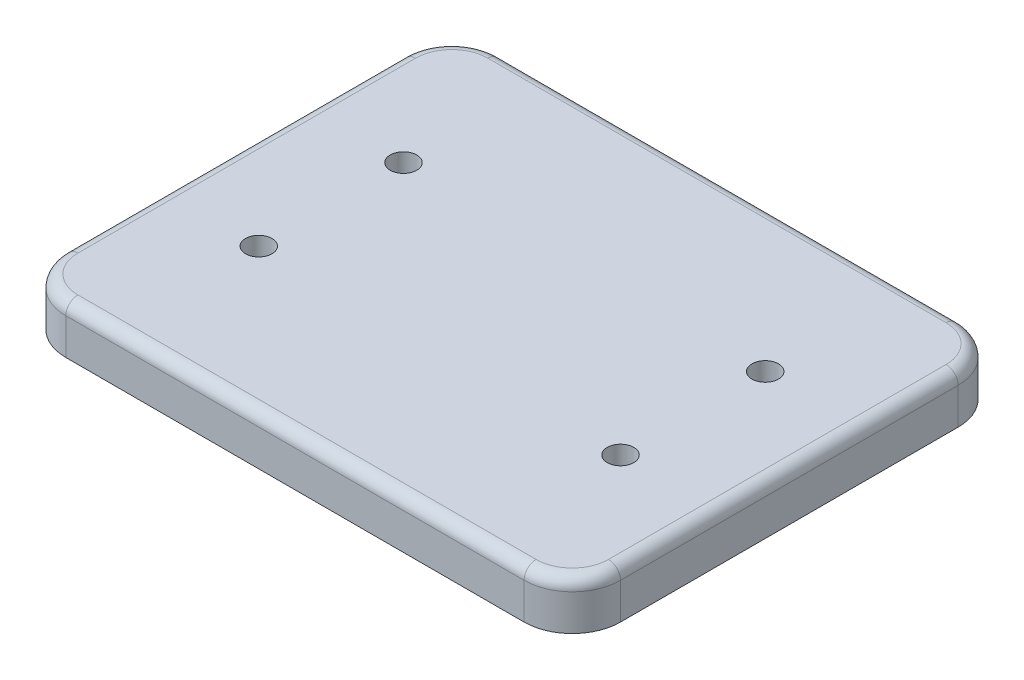
from build123d import *

# Parameters (mm, degrees)
BOSS_EXTRUDE1_DEPTH = 20
FILLET1_R           = 5
SKETCH2_R           = 5.5
CUT_EXTRUDE1_DEPTH  = 21
SKETCH3_R           = 9
CUT_EXTRUDE2_DEPTH  = 11


with BuildPart() as part:
    # Sketch1 → Boss-Extrude1 (new body)
    with BuildSketch(Plane(origin=(0, 0, 0), x_dir=(1, 0, 0), z_dir=(0, 1, 0))):
        with BuildLine():
            Line((-115, 70), (-115, -70))
            ThreePointArc((-115, -70), (-109.142135624, -84.142135624), (-95, -90))
            Line((-95, -90), (95, -90))
            ThreePointArc((95, -90), (109.142135624, -84.142135624), (115, -70))
            Line((115, -70), (115, 70))
            ThreePointArc((115, 70), (109.142135624, 84.142135624), (95, 90))
            Line((95, 90), (-95, 90))
            ThreePointArc((-95, 90), (-109.142135624, 84.142135624), (-115, 70))
        make_face()
    extrude(amount=BOSS_EXTRUDE1_DEPTH)

    # Fillet1
    fillet1_edges = [part.edges().sort_by_distance(p)[0] for p in [
        (109.142135624, 20, 84.142135624),
        (115, 20, 0),
        (109.142135624, 20, -84.142135624),
        (0, 20, -90),
        (-109.142135624, 20, -84.142135624),
        (-115, 20, 0),
        (-109.142135624, 20, 84.142135624),
        (0, 20, 90),
    ]]
    fillet(fillet1_edges, radius=FILLET1_R)

    # Sketch2 → Cut-Extrude1 (cut, through all)
    with BuildSketch(Plane(origin=(0, 20, 0), x_dir=(1, 0, 0), z_dir=(0, 1, 0))):
        with Locations((-75, 30)):
            Circle(SKETCH2_R)
        with Locations((75, 30)):
            Circle(SKETCH2_R)
    cut_extrude1 = extrude(amount=-CUT_EXTRUDE1_DEPTH, mode=Mode.SUBTRACT)

    # Sketch3 → Cut-Extrude2 (cut)
    with BuildSketch(Plane.XZ):
        with Locations((-75, -30)):
            Circle(SKETCH3_R)
        with Locations((75, -30)):
            Circle(SKETCH3_R)
    cut_extrude2 = extrude(amount=-CUT_EXTRUDE2_DEPTH, mode=Mode.SUBTRACT)

    # Mirror1: Cut-Extrude1, Cut-Extrude2 across plane
    add(cut_extrude1.mirror(Plane.XY), mode=Mode.SUBTRACT)
    add(cut_extrude2.mirror(Plane.XY), mode=Mode.SUBTRACT)


solid = part.part
